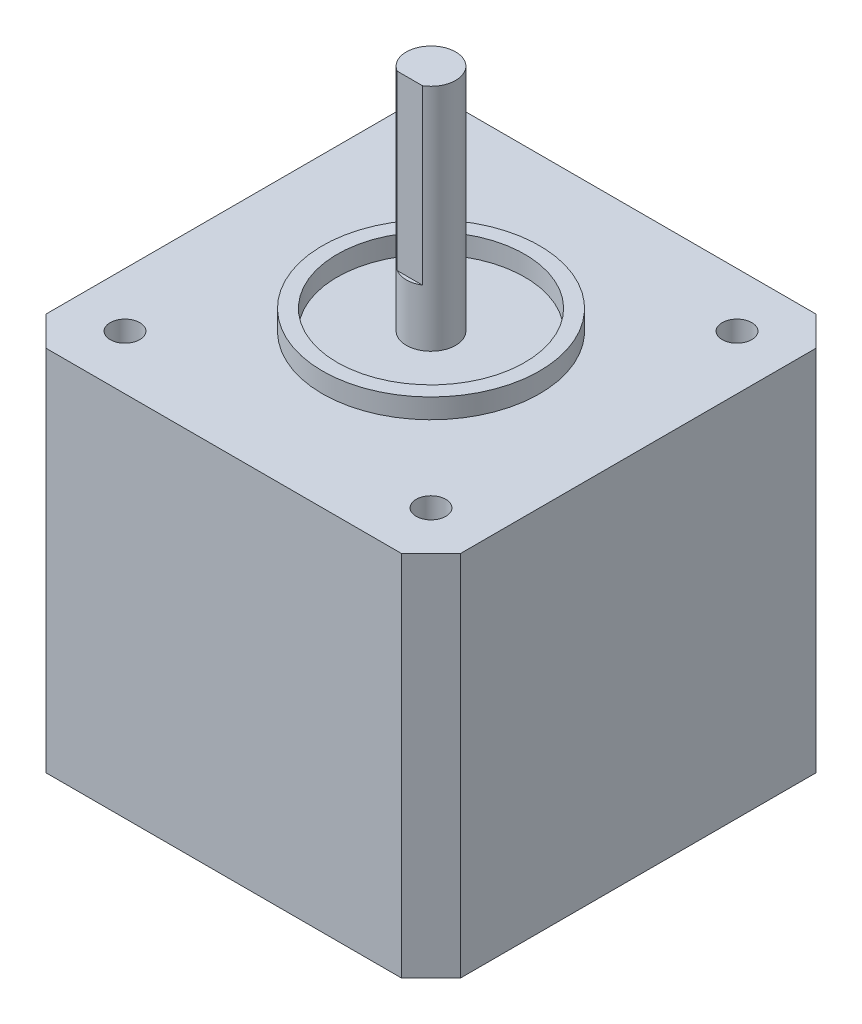
from build123d import *

# Parameters (mm, degrees)
SKETCH1_W           = 42
SKETCH1_H           = 42
BOSS_EXTRUDE1_DEPTH = 37.25
SKETCH2_R           = 1.5
CUT_EXTRUDE1_DEPTH  = 5
SKETCH3_R           = 11
SKETCH3_R_2         = 9.5
BOSS_EXTRUDE2_DEPTH = 2
BOSS_EXTRUDE3_DEPTH = 23.25
CHAMFER1_SIZE       = 3
SKETCH6_R           = 4.5
CUT_EXTRUDE2_DEPTH  = 3.25
SKETCH7_R           = 2.5
BOSS_EXTRUDE4_DEPTH = 5.75


with BuildPart() as part:
    # Sketch1 → Boss-Extrude1 (new body)
    with BuildSketch(Plane(origin=(0, 0, 0), x_dir=(1, 0, 0), z_dir=(0, 1, 0))):
        Rectangle(SKETCH1_W, SKETCH1_H)
    extrude(amount=BOSS_EXTRUDE1_DEPTH)

    # Sketch2 → Cut-Extrude1 (cut)
    with BuildSketch(Plane(origin=(0, 37.25, 0), x_dir=(1, 0, 0), z_dir=(0, 1, 0))):
        with Locations((15.5, 15.5)):
            Circle(SKETCH2_R)
        with Locations((15.5, -15.5)):
            Circle(SKETCH2_R)
        with Locations((-15.5, -15.5)):
            Circle(SKETCH2_R)
        with Locations((-15.5, 15.5)):
            Circle(SKETCH2_R)
    extrude(amount=-CUT_EXTRUDE1_DEPTH, mode=Mode.SUBTRACT)

    # Sketch3 → Boss-Extrude2 (add)
    with BuildSketch(Plane(origin=(0, 37.25, 0), x_dir=(1, 0, 0), z_dir=(0, 1, 0))):
        Circle(SKETCH3_R)
        Circle(SKETCH3_R_2, mode=Mode.SUBTRACT)
    extrude(amount=BOSS_EXTRUDE2_DEPTH)

    # Chamfer1
    chamfer1_edges = [part.edges().sort_by_distance(p)[0] for p in [
        (21, 18.625, 21),
        (-21, 18.625, 21),
        (-21, 18.625, -21),
        (21, 18.625, -21),
    ]]
    chamfer(chamfer1_edges, length=CHAMFER1_SIZE)

    # Sketch6 → Cut-Extrude2 (cut)
    with BuildSketch(Plane.XZ):
        Circle(SKETCH6_R)
    extrude(amount=-CUT_EXTRUDE2_DEPTH, mode=Mode.SUBTRACT)



with BuildPart() as body_2:
    # Sketch4 → Boss-Extrude3 (new body)
    with BuildSketch(Plane(origin=(0, 60.5, 0), x_dir=(1, 0, 0), z_dir=(0, 1, 0))):
        with BuildLine():
            Line((-1.275735082, -2.15), (1.275735082, -2.15))
            ThreePointArc((1.275735082, -2.15), (0, 2.5), (-1.275735082, -2.15))
        make_face()
    extrude(amount=-BOSS_EXTRUDE3_DEPTH)


with BuildPart() as part_1:
    add(part.part)

    add(body_2.part)  # Boss-Extrude4 merges body 2
    # Sketch7 → Boss-Extrude4 (add)
    with BuildSketch(Plane(origin=(0, 37.25, 0), x_dir=(1, 0, 0), z_dir=(0, 1, 0))):
        Circle(SKETCH7_R)
    extrude(amount=BOSS_EXTRUDE4_DEPTH)


solid = part_1.part
